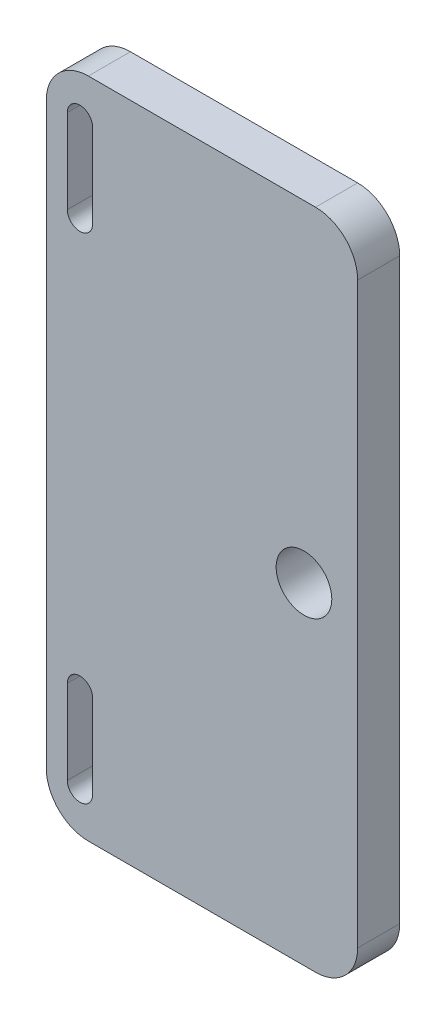
from build123d import *

# Parameters (mm, degrees)
SKETCH1_W           = 19.05
SKETCH1_H           = 50
SKETCH1_R           = 2.1
BOSS_EXTRUDE1_DEPTH = 3.175
SKETCH2_W           = 4.445
SKETCH2_H           = 50
BOSS_EXTRUDE2_DEPTH = 3.175
CUT_EXTRUDE1_DEPTH  = 3.175
FILLET1_R           = 3.175


with BuildPart() as part:
    # Sketch1 → Boss-Extrude1 (new body)
    with BuildSketch(Plane.XY):
        with Locations((-15.475, 0)):
            Rectangle(SKETCH1_W, SKETCH1_H)
        with Locations((-10, 0)):
            Circle(SKETCH1_R, mode=Mode.SUBTRACT)
    extrude(amount=BOSS_EXTRUDE1_DEPTH)

    # Sketch2 → Boss-Extrude2 (add)
    with BuildSketch(Plane.XY.offset(3.175)):
        with Locations((-27.2225, 0)):
            Rectangle(SKETCH2_W, SKETCH2_H)
    extrude(amount=-BOSS_EXTRUDE2_DEPTH)

    # Sketch3 → Cut-Extrude1 (cut)
    with BuildSketch(Plane.XY.offset(3.175)):
        with BuildLine():
            Line((-25.9525, -15.475), (-25.9525, -21.825))
            ThreePointArc((-25.9525, -21.825), (-26.905, -22.7775), (-27.8575, -21.825))
            Line((-27.8575, -21.825), (-27.8575, -15.475))
            ThreePointArc((-27.8575, -15.475), (-26.905, -14.5225), (-25.9525, -15.475))
        make_face()
        with BuildLine():
            Line((-25.9525, 15.475), (-25.9525, 21.825))
            ThreePointArc((-25.9525, 21.825), (-26.905, 22.7775), (-27.8575, 21.825))
            Line((-27.8575, 21.825), (-27.8575, 15.475))
            ThreePointArc((-27.8575, 15.475), (-26.905, 14.5225), (-25.9525, 15.475))
        make_face()
    extrude(amount=-CUT_EXTRUDE1_DEPTH, mode=Mode.SUBTRACT)

    # Fillet1
    fillet1_edges = [part.edges().sort_by_distance(p)[0] for p in [
        (-29.445, -25, 1.5875),
        (-29.445, 25, 1.5875),
        (-5.95, 25, 1.5875),
        (-5.95, -25, 1.5875),
    ]]
    fillet(fillet1_edges, radius=FILLET1_R)


solid = part.part
